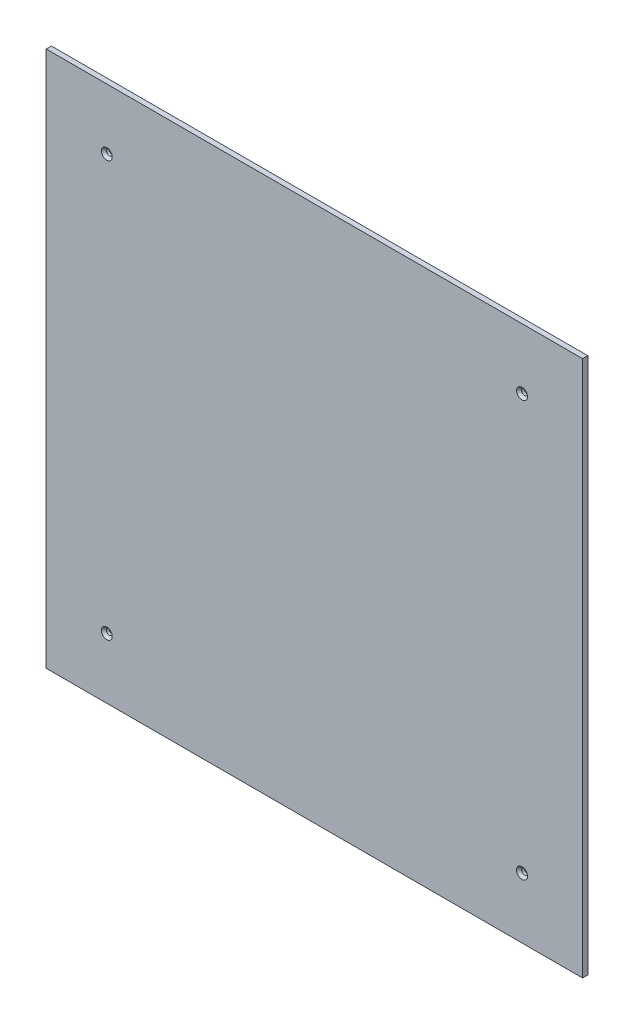
from build123d import *

# Parameters (mm, degrees)
SKETCH_1_W                  = 310
SKETCH_1_H                  = 310
EXTRUDE_1_DEPTH             = 3
HOLE_WIZARD_M3_1_AT_2_COUNT = 2
HOLE_WIZARD_M3_1_AT_2_PITCH = 240
HOLE_WIZARD_M3_1_AT_3_COUNT = 2
HOLE_WIZARD_M3_1_AT_3_PITCH = 339.41125497
HOLE_WIZARD_M3_1_AT_4_COUNT = 2
HOLE_WIZARD_M3_1_AT_4_PITCH = 240


with BuildPart() as part:
    # 草图1 → 凸台-拉伸1 (new body)
    with BuildSketch(Plane.XY):
        with Locations((11.704805492, -50.011441648)):
            Rectangle(SKETCH_1_W, SKETCH_1_H)
    extrude(amount=-EXTRUDE_1_DEPTH)

    # 草图3 → M3 平头机械螺钉的锥形沉头孔1 (revolve, cut)
    with BuildSketch(Plane(origin=(-108.295194508, 69.988558352, 0), x_dir=(0, -1, 0), z_dir=(1, 0, 0))):
        Polygon((0, 0), (0, 3), (1.7, 3), (1.7, 1.45), (3.15, 0), align=None)
    hole_wizard_m3_1 = revolve(axis=Axis((-108.295194508, 69.988558352, 6.35), (0, 0, -1)), mode=Mode.SUBTRACT)

    # M3 平头机械螺钉的锥形沉头孔1 at 2: M3 平头机械螺钉的锥形沉头孔1 ×2
    with Locations(*[(i * HOLE_WIZARD_M3_1_AT_2_PITCH, 0, 0) for i in range(1, HOLE_WIZARD_M3_1_AT_2_COUNT)]):
        add(hole_wizard_m3_1, mode=Mode.SUBTRACT)

    # M3 平头机械螺钉的锥形沉头孔1 at 3: M3 平头机械螺钉的锥形沉头孔1 ×2
    with Locations(*[Vector(0.707106781, -0.707106781, 0) * (i * HOLE_WIZARD_M3_1_AT_3_PITCH) for i in range(1, HOLE_WIZARD_M3_1_AT_3_COUNT)]):
        add(hole_wizard_m3_1, mode=Mode.SUBTRACT)

    # M3 平头机械螺钉的锥形沉头孔1 at 4: M3 平头机械螺钉的锥形沉头孔1 ×2
    with Locations(*[(0, -i * HOLE_WIZARD_M3_1_AT_4_PITCH, 0) for i in range(1, HOLE_WIZARD_M3_1_AT_4_COUNT)]):
        add(hole_wizard_m3_1, mode=Mode.SUBTRACT)


solid = part.part
